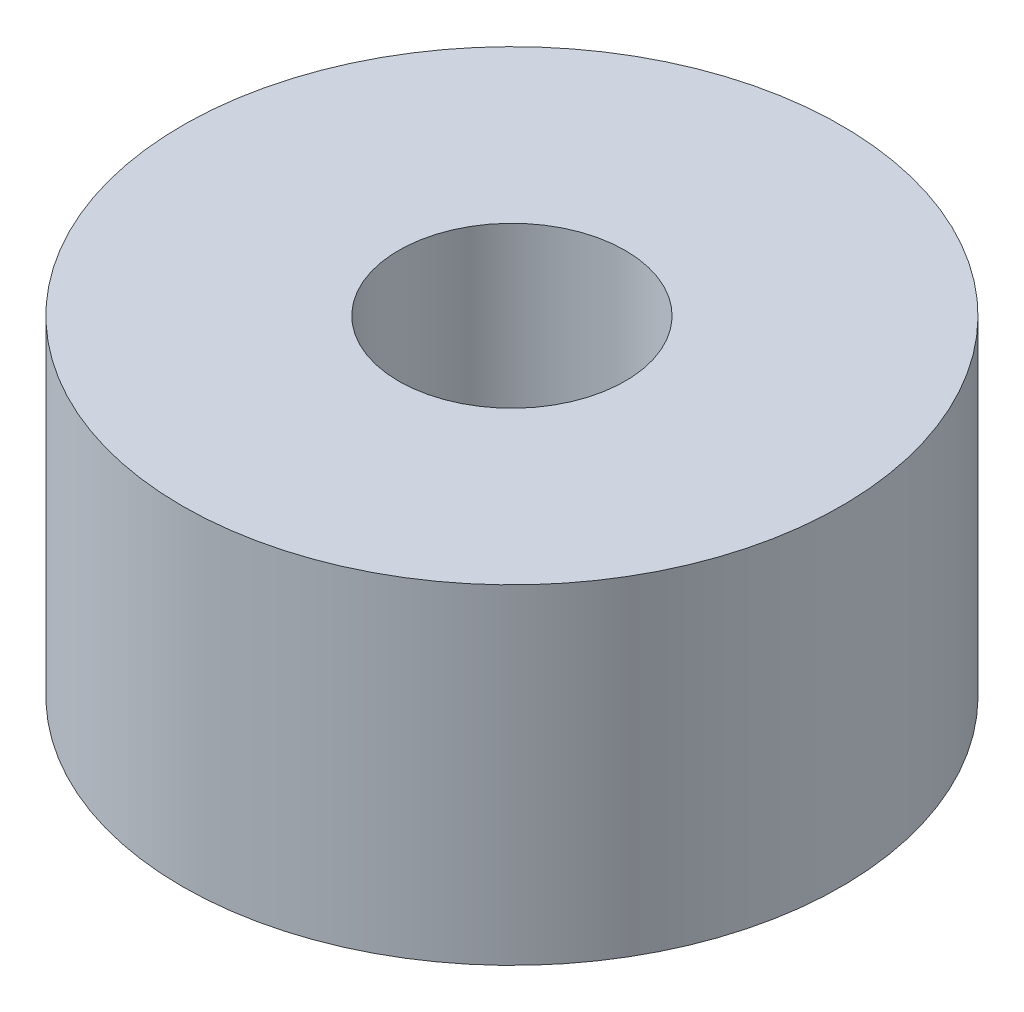
from build123d import *

# Parameters (mm, degrees)
SKETCH1_R           = 6.35
SKETCH1_R_2         = 2.1828125
BOSS_EXTRUDE1_DEPTH = 6.35


with BuildPart() as part:
    # Sketch1 → Boss-Extrude1 (new body)
    with BuildSketch(Plane(origin=(0, 0, 0), x_dir=(1, 0, 0), z_dir=(0, 1, 0))):
        Circle(SKETCH1_R)
        Circle(SKETCH1_R_2, mode=Mode.SUBTRACT)
    extrude(amount=BOSS_EXTRUDE1_DEPTH)


solid = part.part
